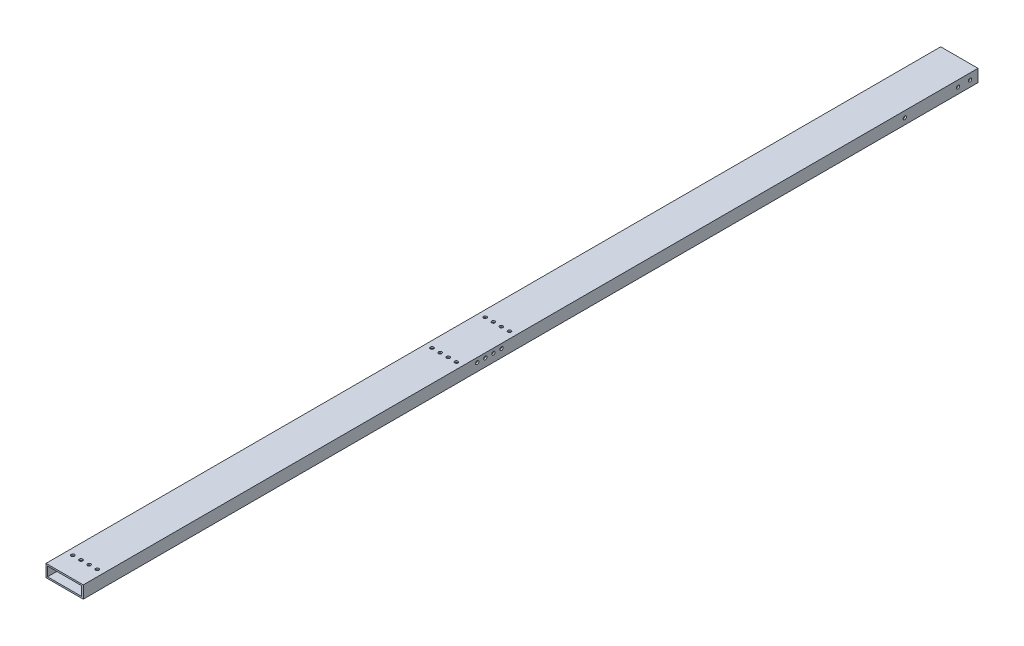
from build123d import *

# Parameters (mm, degrees)
SKETCH1_W           = 76.2
SKETCH1_H           = 25.4
SKETCH1_W_2         = 69.85
SKETCH1_H_2         = 19.05
BOSS_EXTRUDE1_DEPTH = 1828.8
SKETCH3_R           = 3.3782
CUT_EXTRUDE1_DEPTH  = 26.4
SKETCH4_R           = 3.3782
CUT_EXTRUDE2_DEPTH  = 77.2
SKETCH5_R           = 3.3782
CUT_EXTRUDE3_DEPTH  = 26.4
SKETCH6_R           = 3.3782
CUT_EXTRUDE4_DEPTH  = 26.4
SKETCH7_R           = 3.3782
CUT_EXTRUDE5_DEPTH  = 77.2


with BuildPart() as part:
    # Sketch1 → Boss-Extrude1 (new body)
    with BuildSketch(Plane.XY):
        with Locations((38.1, 12.7)):
            Rectangle(SKETCH1_W, SKETCH1_H)
        with Locations((38.1, 12.7)):
            Rectangle(SKETCH1_W_2, SKETCH1_H_2, mode=Mode.SUBTRACT)
    extrude(amount=BOSS_EXTRUDE1_DEPTH)

    # Sketch3 → Cut-Extrude1 (cut, through all)
    with BuildSketch(Plane.XZ):
        with Locations((13.21308, 1787.1313)):
            Circle(SKETCH3_R)
        with Locations((29.80436, 1787.1313)):
            Circle(SKETCH3_R)
        with Locations((46.39564, 1787.1313)):
            Circle(SKETCH3_R)
        with Locations((62.98692, 1787.1313)):
            Circle(SKETCH3_R)
    extrude(amount=-CUT_EXTRUDE1_DEPTH, mode=Mode.SUBTRACT)

    # Sketch4 → Cut-Extrude2 (cut, through all)
    with BuildSketch(Plane(origin=(76.2, 0, 0), x_dir=(0, 0, -1), z_dir=(1, 0, 0))):
        with Locations((-1023.590915732, 16.2687)):
            Circle(SKETCH4_R)
        with Locations((-1006.999635732, 16.2687)):
            Circle(SKETCH4_R)
        with Locations((-990.408355732, 16.2687)):
            Circle(SKETCH4_R)
        with Locations((-973.817075732, 16.2687)):
            Circle(SKETCH4_R)
    extrude(amount=-CUT_EXTRUDE2_DEPTH, mode=Mode.SUBTRACT)

    # Sketch5 → Cut-Extrude3 (cut, through all)
    with BuildSketch(Plane.XZ):
        with Locations((13.21308, 1053.072695732)):
            Circle(SKETCH5_R)
        with Locations((29.80436, 1053.072695732)):
            Circle(SKETCH5_R)
        with Locations((46.39564, 1053.072695732)):
            Circle(SKETCH5_R)
        with Locations((62.98692, 1053.072695732)):
            Circle(SKETCH5_R)
    extrude(amount=-CUT_EXTRUDE3_DEPTH, mode=Mode.SUBTRACT)

    # Sketch6 → Cut-Extrude4 (cut, through all)
    with BuildSketch(Plane.XZ):
        with Locations((13.21308, 944.335295732)):
            Circle(SKETCH6_R)
        with Locations((46.39564, 944.335295732)):
            Circle(SKETCH6_R)
        with Locations((62.98692, 944.335295732)):
            Circle(SKETCH6_R)
        with Locations((29.80436, 944.335295732)):
            Circle(SKETCH6_R)
    extrude(amount=-CUT_EXTRUDE4_DEPTH, mode=Mode.SUBTRACT)

    # Sketch7 → Cut-Extrude5 (cut, through all)
    with BuildSketch(Plane(origin=(76.2, 0, 0), x_dir=(0, 0, -1), z_dir=(1, 0, 0))):
        with Locations((-16.2687, 12.7)):
            Circle(SKETCH7_R)
        with Locations((-40.894858719, 12.7)):
            Circle(SKETCH7_R)
        with Locations((-149.632258719, 12.7)):
            Circle(SKETCH7_R)
    extrude(amount=-CUT_EXTRUDE5_DEPTH, mode=Mode.SUBTRACT)


solid = part.part
